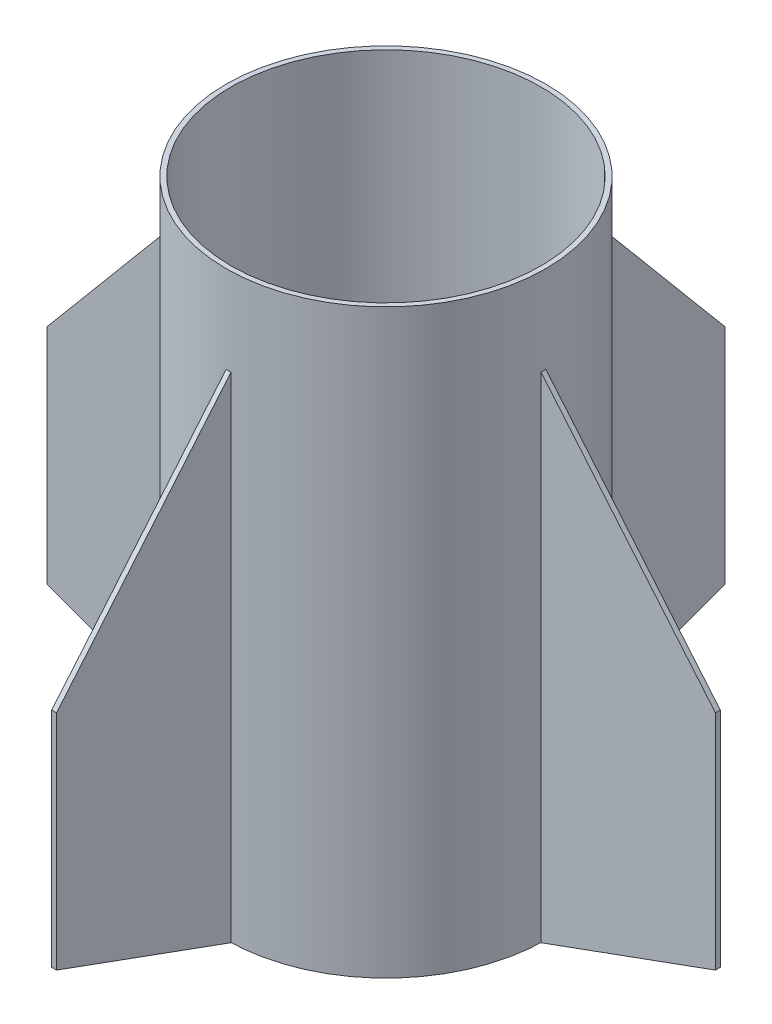
from build123d import *

# Parameters (mm, degrees)
SKETCH1_R           = 104.775
SKETCH1_R_2         = 101.6
BOSS_EXTRUDE1_DEPTH = 381
BOSS_EXTRUDE2_DEPTH = 3.175
BOSS_EXTRUDE3_DEPTH = 3.175
BOSS_EXTRUDE4_DEPTH = 3.175
BOSS_EXTRUDE5_DEPTH = 3.175


with BuildPart() as part:
    # Sketch1 → Boss-Extrude1 (new body)
    with BuildSketch(Plane(origin=(0, 0, 0), x_dir=(1, 0, 0), z_dir=(0, 1, 0))):
        Circle(SKETCH1_R)
        Circle(SKETCH1_R_2, mode=Mode.SUBTRACT)
    extrude(amount=BOSS_EXTRUDE1_DEPTH)


with BuildPart() as body_2:
    # Sketch2 → Boss-Extrude2 (new body)
    with BuildSketch(Plane(origin=(0, 0, 0), x_dir=(0, 0, -1), z_dir=(1, 0, 0))):
        Polygon((-104.775, 323.85), (-219.075, 187.657672757), (-219.075, 41.607672757), (-104.775, 0), align=None)
    extrude(amount=BOSS_EXTRUDE2_DEPTH)


with BuildPart() as body_3:
    # Sketch5 → Boss-Extrude3 (new body)
    with BuildSketch(Plane(origin=(0, 0, 0), x_dir=(0, 0, -1), z_dir=(1, 0, 0))):
        Polygon((104.775, 323.85), (219.075, 187.657672757), (219.075, 41.607672757), (104.775, 0), align=None)
    extrude(amount=BOSS_EXTRUDE3_DEPTH)


with BuildPart() as body_4:
    # Sketch6 → Boss-Extrude4 (new body)
    with BuildSketch(Plane.XY):
        Polygon((-104.775, 323.85), (-219.075, 187.657672757), (-219.075, 41.607672757), (-104.775, 0), align=None)
    extrude(amount=BOSS_EXTRUDE4_DEPTH)


with BuildPart() as body_5:
    # Sketch7 → Boss-Extrude5 (new body)
    with BuildSketch(Plane.XY):
        Polygon((104.775, 323.85), (219.075, 187.657672757), (219.075, 41.607672757), (104.775, 0), align=None)
    extrude(amount=BOSS_EXTRUDE5_DEPTH)


solid = Compound([part.part, body_2.part, body_3.part, body_4.part, body_5.part])
